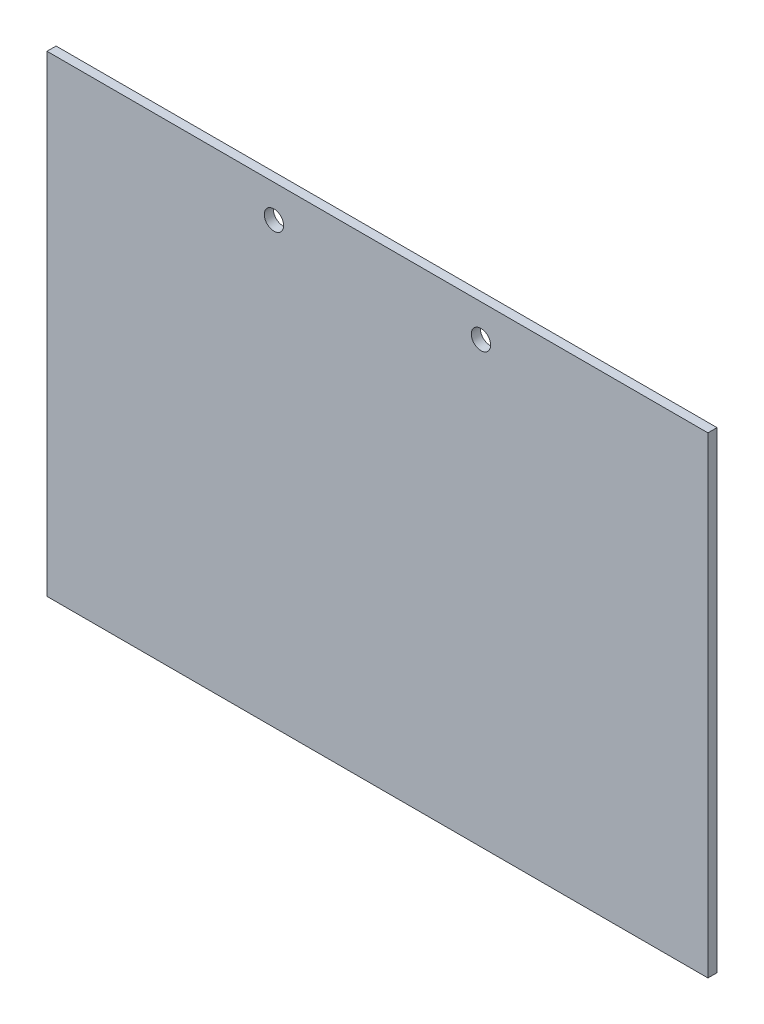
from build123d import *

# Parameters (mm, degrees)
SKETCH1_W               = 231.14
SKETCH1_H               = 165.1
BOSS_EXTRUDE1_DEPTH     = 3.175
F_1_4_CLEARANCE_HOLE1_D = 6.7564


with BuildPart() as part:
    # Sketch1 → Boss-Extrude1 (new body)
    with BuildSketch(Plane.XY):
        with Locations((115.57, -82.55)):
            Rectangle(SKETCH1_W, SKETCH1_H)
    extrude(amount=BOSS_EXTRUDE1_DEPTH)

    # 1/4 Clearance Hole1 (through all)
    with Locations(Plane.XY.offset(3.175)):
        with Locations((79.375, -11.43), (151.765, -11.43)):
            Hole(F_1_4_CLEARANCE_HOLE1_D / 2)


solid = part.part
